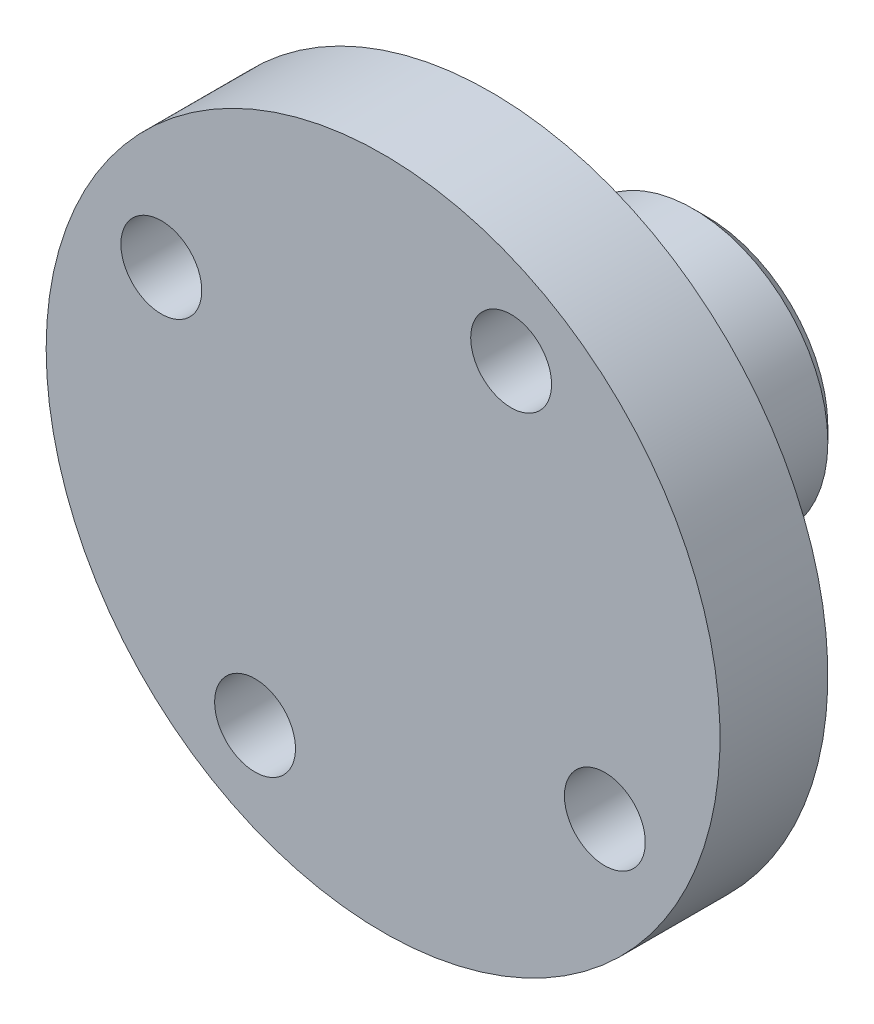
from build123d import *

# Parameters (mm, degrees)
CUT_EXTRUDE1_REACH      = 6
SKETCH13_R              = 1.5
SKETCH5_R               = 1.5
CUT_EXTRUDE2_DEPTH      = 13.5
CUT_EXTRUDE2_DEPTH_BACK = 13.5
CHAMFER1_SIZE           = 0.5


with BuildPart() as part:
    # Sketch1 → Revolve1 (revolve)
    with BuildSketch(Plane(origin=(0, 0, 0), x_dir=(1, 0, 0), z_dir=(0, 1, 0))):
        Polygon((0, 0), (0, 4), (4, 4), (4, 12), (5, 12), (5, 4), (12.5, 4), (12.5, 0), align=None)
    revolve(axis=Axis((0, 0, 0), (0, 0, 1)))

    # Sketch13 → Cut-Extrude1 (cut, up to next)
    with BuildSketch(Plane(origin=(0, 0, -4), x_dir=(-1, 0, 0), z_dir=(0, 0, -1)), mode=Mode.PRIVATE) as cut_extrude1_sk1:
        with Locations((-4.75, 8.227241336)):
            Circle(SKETCH13_R)
    cut_extrude1_tool1 = extrude(cut_extrude1_sk1.sketch, amount=-CUT_EXTRUDE1_REACH, mode=Mode.PRIVATE) & part.part
    add(cut_extrude1_tool1.solids().sort_by_distance((4.75, 8.227241, -4))[0], mode=Mode.SUBTRACT)
    # Sketch13 → Cut-Extrude1 (cut, up to next)
    with BuildSketch(Plane(origin=(0, 0, -4), x_dir=(-1, 0, 0), z_dir=(0, 0, -1)), mode=Mode.PRIVATE) as cut_extrude1_sk2:
        with Locations((-8.227241336, -4.75)):
            Circle(SKETCH13_R)
    cut_extrude1_tool2 = extrude(cut_extrude1_sk2.sketch, amount=-CUT_EXTRUDE1_REACH, mode=Mode.PRIVATE) & part.part
    add(cut_extrude1_tool2.solids().sort_by_distance((8.227241, -4.75, -4))[0], mode=Mode.SUBTRACT)
    # Sketch13 → Cut-Extrude1 (cut, up to next)
    with BuildSketch(Plane(origin=(0, 0, -4), x_dir=(-1, 0, 0), z_dir=(0, 0, -1)), mode=Mode.PRIVATE) as cut_extrude1_sk3:
        with Locations((4.75, -8.227241336)):
            Circle(SKETCH13_R)
    cut_extrude1_tool3 = extrude(cut_extrude1_sk3.sketch, amount=-CUT_EXTRUDE1_REACH, mode=Mode.PRIVATE) & part.part
    add(cut_extrude1_tool3.solids().sort_by_distance((-4.75, -8.227241, -4))[0], mode=Mode.SUBTRACT)
    # Sketch13 → Cut-Extrude1 (cut, up to next)
    with BuildSketch(Plane(origin=(0, 0, -4), x_dir=(-1, 0, 0), z_dir=(0, 0, -1)), mode=Mode.PRIVATE) as cut_extrude1_sk4:
        with Locations((8.227241336, 4.75)):
            Circle(SKETCH13_R)
    cut_extrude1_tool4 = extrude(cut_extrude1_sk4.sketch, amount=-CUT_EXTRUDE1_REACH, mode=Mode.PRIVATE) & part.part
    add(cut_extrude1_tool4.solids().sort_by_distance((-8.227241, 4.75, -4))[0], mode=Mode.SUBTRACT)

    # Sketch5 → Cut-Extrude2 (cut, two sides)
    with BuildSketch(Plane(origin=(0, 0, 0), x_dir=(0, 0, -1), z_dir=(1, 0, 0))) as cut_extrude2_sk:
        with Locations((8, 0)):
            Circle(SKETCH5_R)
    extrude(amount=CUT_EXTRUDE2_DEPTH, mode=Mode.SUBTRACT)
    extrude(cut_extrude2_sk.sketch, amount=-CUT_EXTRUDE2_DEPTH_BACK, mode=Mode.SUBTRACT)

    # Chamfer1
    chamfer1_edges = [part.edges().sort_by_distance(p)[0] for p in [
        (-5, 0, -12),
    ]]
    chamfer(chamfer1_edges, length=CHAMFER1_SIZE)


solid = part.part
